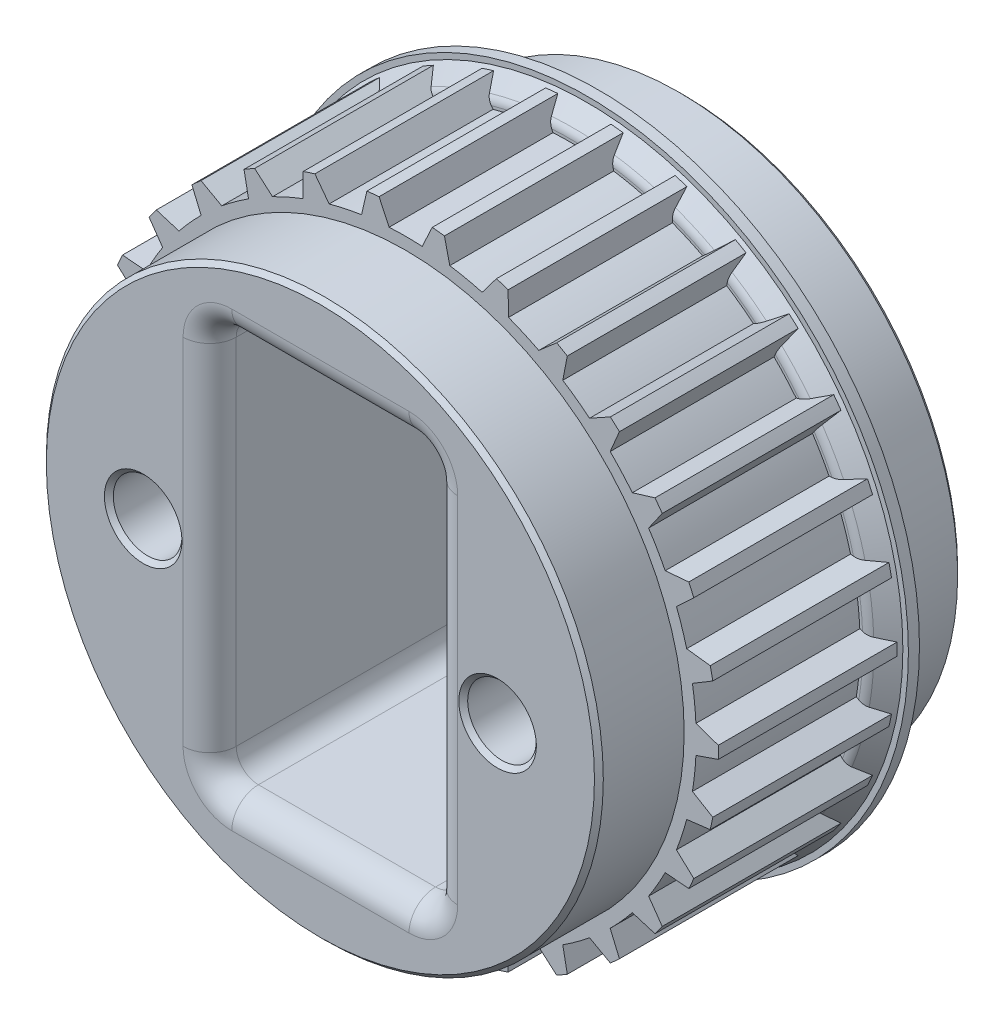
from build123d import *

# Parameters (mm, degrees)
SCHNITT_LINEAR_AUSTRAGEN1_DEPTH      = 22.586773728
KREISMUSTER1_COUNT                   = 30
SCHNITT_LINEAR_AUSTRAGEN2_DEPTH      = 23.084836427
SCHNITT_LINEAR_AUSTRAGEN2_DEPTH_BACK = 23.084836427
SKIZZE4_R                            = 1.55
VERRUNDUNG1_R                        = 1.2
FASE1_SIZE                           = 0.2


with BuildPart() as part:
    # Skizze1 → Rotation1 (revolve)
    with BuildSketch(Plane(origin=(0, 0, 0), x_dir=(0, 0, -1), z_dir=(1, 0, 0))):
        Polygon((-4.35, 14.12), (4.35, 14.12), (4.35, 12.575), (8.2, 12.575), (8.2, 0), (-8.2, 0), (-8.2, 12.575), (-4.35, 12.575), align=None)
    revolve(axis=Axis((0, 0, 46.515199561), (0, 0, -1)))

    # Skizze2 → Schnitt-Linear austragen1 (cut, symmetric)
    with BuildSketch(Plane.XY):
        with BuildLine():
            Line((-1.2, 14.068916092), (-0.747573546, 13.09868443))
            ThreePointArc((-0.747573546, 13.09868443), (0, 13.12), (0.747573546, 13.09868443))
            Line((0.747573546, 13.09868443), (1.2, 14.068916092))
            ThreePointArc((1.2, 14.068916092), (0, 14.12), (-1.2, 14.068916092))
        make_face()
    schnitt_linear_austragen1 = extrude(amount=SCHNITT_LINEAR_AUSTRAGEN1_DEPTH, both=True, mode=Mode.SUBTRACT)

    # Kreismuster1: Schnitt-Linear austragen1 ×30 about axis
    kreismuster1_axis = Axis((0, 0, 9.02), (0, 0, -1))
    for i in range(1, KREISMUSTER1_COUNT):
        add(schnitt_linear_austragen1.rotate(kreismuster1_axis, i * 360 / KREISMUSTER1_COUNT), mode=Mode.SUBTRACT)

    # Skizze3 → Rotation2 (revolve)
    with BuildSketch(Plane(origin=(0, 0, 0), x_dir=(0, 0, -1), z_dir=(1, 0, 0))):
        with BuildLine():
            Line((4.35, 13), (4.35, 14.5))
            Line((4.35, 14.5), (3.85, 14.5))
            Line((3.85, 14.5), (3.85, 14.25))
            Line((3.85, 14.25), (3.196446609, 13.596446609))
            ThreePointArc((3.196446609, 13.596446609), (3.088060234, 13.434234935), (3.05, 13.242893219))
            Line((3.05, 13.242893219), (3.05, 13))
            Line((3.05, 13), (4.35, 13))
        make_face()
    revolve(axis=Axis((0, 0, -11.03129214), (0, 0, 1)))

    # Skizze4 → Schnitt-Linear austragen2 (cut, two sides: drawn at the far end of the back side and taken through both)
    with BuildSketch(Plane.XY.offset(-SCHNITT_LINEAR_AUSTRAGEN2_DEPTH_BACK)):
        with Locations((-8, 0)):
            Circle(SKIZZE4_R)
        with Locations((8, 0)):
            Circle(SKIZZE4_R)
        with BuildLine():
            Line((4, 9), (-4, 9))
            ThreePointArc((-4, 9), (-4.707106781, 8.707106781), (-5, 8))
            Line((-5, 8), (-5, -8))
            ThreePointArc((-5, -8), (-4.707106781, -8.707106781), (-4, -9))
            Line((-4, -9), (4, -9))
            ThreePointArc((4, -9), (4.707106781, -8.707106781), (5, -8))
            Line((5, -8), (5, 8))
            ThreePointArc((5, 8), (4.707106781, 8.707106781), (4, 9))
        make_face()
    extrude(amount=SCHNITT_LINEAR_AUSTRAGEN2_DEPTH + SCHNITT_LINEAR_AUSTRAGEN2_DEPTH_BACK, mode=Mode.SUBTRACT)

    # Verrundung1
    verrundung1_edges = [part.edges().sort_by_distance(p)[0] for p in [
        (-4.707106781, 8.707106781, -8.2),
        (0, 9, -8.2),
        (4.707106781, 8.707106781, -8.2),
        (5, 0, -8.2),
        (4.707106781, -8.707106781, -8.2),
        (0, -9, -8.2),
        (-4.707106781, -8.707106781, -8.2),
        (-4.707106781, 8.707106781, 8.2),
        (0, 9, 8.2),
        (4.707106781, 8.707106781, 8.2),
        (5, 0, 8.2),
        (4.707106781, -8.707106781, 8.2),
        (0, -9, 8.2),
        (-4.707106781, -8.707106781, 8.2),
        (-5, 0, -8.2),
        (-5, 0, 8.2),
    ]]
    fillet(verrundung1_edges, radius=VERRUNDUNG1_R)

    # Fase1
    fase1_edges = [part.edges().sort_by_distance(p)[0] for p in [
        (-9.55, 0, -8.2),
        (6.45, 0, -8.2),
        (6.45, 0, 8.2),
        (-9.55, 0, 8.2),
        (0, -12.575, -8.2),
        (0, -12.575, 8.2),
    ]]
    chamfer(fase1_edges, length=FASE1_SIZE)


solid = part.part
